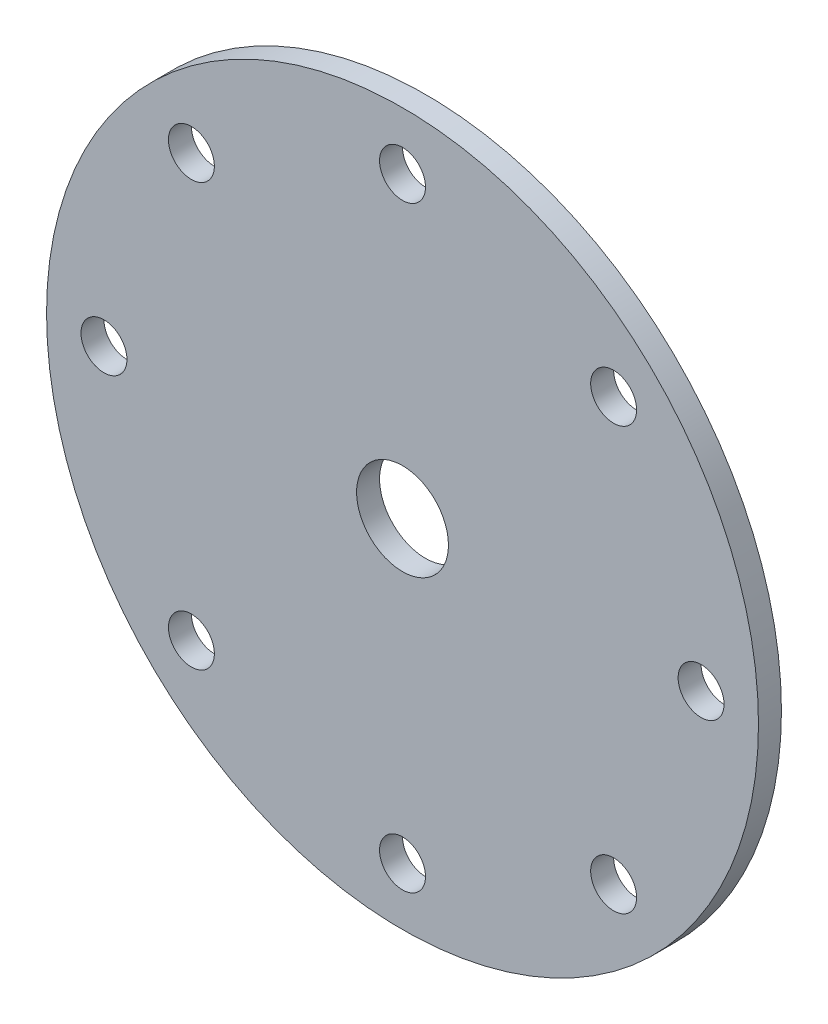
from build123d import *

# Parameters (mm, degrees)
SKETCH1_R        = 98.425
SKETCH1_R_2      = 12.7
SKETCH1_R_3      = 6.35
ROTOR_DISC_DEPTH = 6.35


with BuildPart() as part:
    # Sketch1 → Rotor Disc (new body)
    with BuildSketch(Plane.XY):
        Circle(SKETCH1_R)
        Circle(SKETCH1_R_2, mode=Mode.SUBTRACT)
        with Locations((0, 82.55)):
            Circle(SKETCH1_R_3, mode=Mode.SUBTRACT)
        with Locations((58.371664787, 58.371664787)):
            Circle(SKETCH1_R_3, mode=Mode.SUBTRACT)
        with Locations((82.55, 0)):
            Circle(SKETCH1_R_3, mode=Mode.SUBTRACT)
        with Locations((58.371664787, -58.371664787)):
            Circle(SKETCH1_R_3, mode=Mode.SUBTRACT)
        with Locations((0, -82.55)):
            Circle(SKETCH1_R_3, mode=Mode.SUBTRACT)
        with Locations((-58.371664787, -58.371664787)):
            Circle(SKETCH1_R_3, mode=Mode.SUBTRACT)
        with Locations((-82.55, 0)):
            Circle(SKETCH1_R_3, mode=Mode.SUBTRACT)
        with Locations((-58.371664787, 58.371664787)):
            Circle(SKETCH1_R_3, mode=Mode.SUBTRACT)
    extrude(amount=ROTOR_DISC_DEPTH)


solid = part.part
